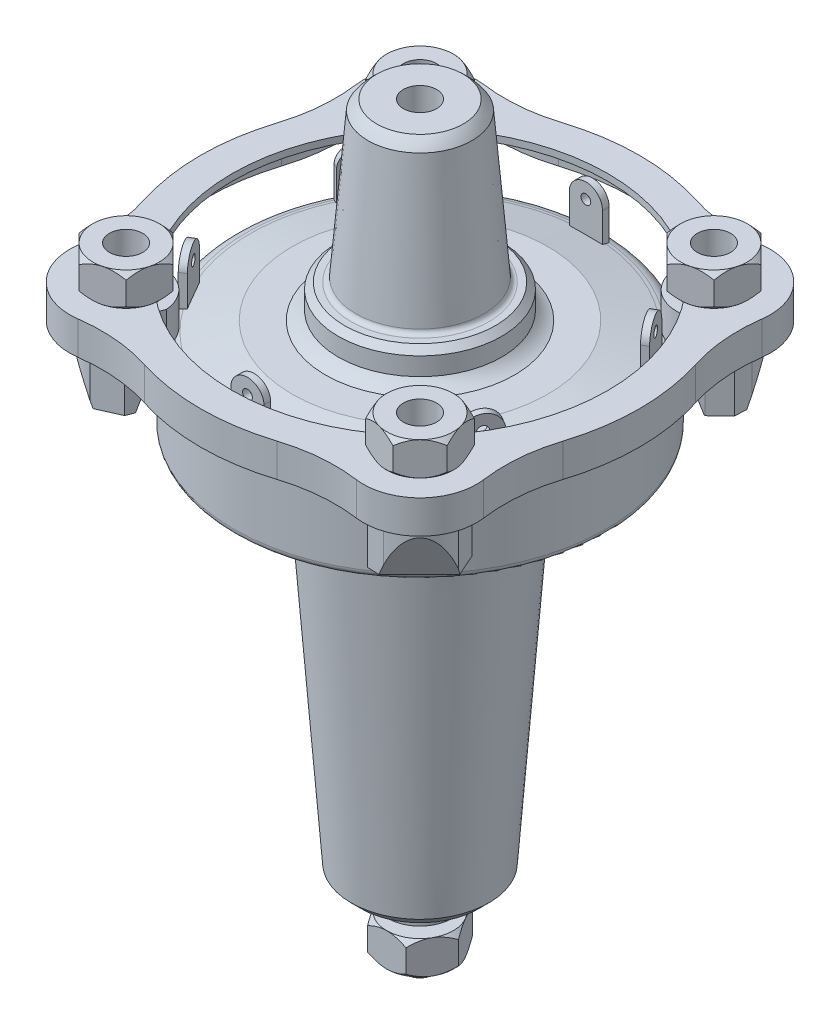
from build123d import *

# Parameters (mm, degrees)
BOSS_EXTRUDE1_DEPTH     = 10
SHELL1_T                = -2
BOSS_EXTRUDE2_DEPTH     = 25
CUT_EXTRUDE1_START      = -56.000013
CUT_EXTRUDE1_DEPTH      = 112.000026
CUT_EXTRUDE2_DEPTH      = 25
CUT_EXTRUDE2_DEPTH_BACK = 25
BOSS_EXTRUDE4_START     = 4
SKETCH11_R              = 5
BOSS_EXTRUDE4_DEPTH     = 55
BOSS_EXTRUDE5_START     = 0.2
SKETCH12_R              = 5
BOSS_EXTRUDE5_DEPTH     = 10
CIRPATTERN2_COUNT       = 4
BOSS_EXTRUDE6_START     = 3
SKETCH16_R              = 5
BOSS_EXTRUDE6_DEPTH     = 10
BOSS_EXTRUDE7_START     = 23
SKETCH19_W              = 10
SKETCH19_H              = 2
BOSS_EXTRUDE7_DEPTH     = 17
CUT_EXTRUDE3_DEPTH      = 3
SKETCH21_R              = 1.468360271
CUT_EXTRUDE4_DEPTH      = 2
CIRPATTERN3_COUNT       = 6
SKETCH22_R              = 5
CUT_EXTRUDE5_DEPTH      = 55


with BuildPart() as part:
    # Sketch1 → Revolve1 (revolve)
    with BuildSketch(Plane.XY, mode=Mode.PRIVATE) as revolve1_sk:
        with BuildLine():
            Line((-56, 20.318064045), (-56, 2.002164861))
            ThreePointArc((-56, 2.002164861), (-55.475282644, 0.643624038), (-54.168871694, 0))
            Line((-54.168871694, 0), (-40.294275716, 0))
            ThreePointArc((-40.294275716, 0), (-38.685602359, -0.47223007), (-38, -2.002191055))
            Line((-38, -2.002191055), (-38, -8))
            Line((-38, -8), (-33, -8))
            ThreePointArc((-33, -8), (-29.595355115, -9.338252711), (-28.013220329, -12.636642718))
            Line((-28.013220329, -12.636642718), (-20.700333224, -113))
            Line((-20.700333224, -113), (-17.700333224, -116))
            Line((-17.700333224, -116), (-5.005495065, -116))
            Line((-5.005495065, -116), (-5.005495065, 86))
            Line((-5.005495065, 86), (-13.005495065, 86))
            ThreePointArc((-13.005495065, 86), (-14.431764892, 84.590632691), (-15.652604552, 83))
            Line((-15.652604552, 83), (-19.242395009, 39.684629687))
            ThreePointArc((-19.242395009, 39.684629687), (-19.709520419, 38.7291334), (-20.700333224, 38.342520816))
            Line((-20.700333224, 38.342520816), (-22.700333224, 38.342520816))
            Line((-22.700333224, 38.342520816), (-24.567556452, 36.475294958))
            Line((-24.567556452, 36.475294958), (-24.567556452, 31.062035315))
            ThreePointArc((-24.567556452, 31.062035315), (-26.332636345, 29.455038721), (-28.44909, 28.35115059))
            Line((-28.44909, 28.35115059), (-38.44909, 28.35115059))
            Line((-38.44909, 28.35115059), (-51.056099295, 25.4407569))
            Line((-51.056099295, 25.4407569), (-52.126082775, 25.193981093))
            ThreePointArc((-52.126082775, 25.193981093), (-54.913630569, 23.43181587), (-56, 20.318064045))
        make_face()
    revolve(revolve1_sk.sketch.rotate(Axis((0, 166.474598928, 0), (0, -1, 0)), 270), axis=Axis((0, 166.474598928, 0), (0, -1, 0)))


with BuildPart() as body_2:
    # Sketch2 → Revolve2 (revolve)
    with BuildSketch(Plane.XY, mode=Mode.PRIVATE) as revolve2_sk:
        Polygon((-9.642767104, -116), (-9.642767104, -122.580289549), (-5.005495065, -122.580289549), (-5.005495065, -136), (-4.004428905, -140.07390495), (0, -140.07390495), (0, -116), align=None)
    revolve(revolve2_sk.sketch.rotate(Axis((0, 166.474598928, 0), (0, -1, 0)), 270), axis=Axis((0, 166.474598928, 0), (0, -1, 0)))


with BuildPart() as body_3:
    # Sketch3 → Boss-Extrude1 (new body)
    with BuildSketch(Plane(origin=(0, 28.35115059, 0), x_dir=(1, 0, 0), z_dir=(0, 1, 0))):
        with BuildLine():
            ThreePointArc((-62.91080264, 19.955723771), (-66, 0), (-62.91080264, -19.955723771))
            ThreePointArc((-62.91080264, -19.955723771), (-60.752328752, -30.813455346), (-61.035928635, -41.880022817))
            ThreePointArc((-61.035928635, -41.880022817), (-56.214989104, -56.214989104), (-41.880022817, -61.035928635))
            ThreePointArc((-41.880022817, -61.035928635), (-30.813455346, -60.752328752), (-19.955723771, -62.91080264))
            ThreePointArc((-19.955723771, -62.91080264), (0, -66), (19.955723771, -62.91080264))
            ThreePointArc((19.955723771, -62.91080264), (30.813455346, -60.752328752), (41.880022817, -61.035928635))
            ThreePointArc((41.880022817, -61.035928635), (56.214989104, -56.214989104), (61.035928635, -41.880022817))
            ThreePointArc((61.035928635, -41.880022817), (60.752328752, -30.813455346), (62.91080264, -19.955723771))
            ThreePointArc((62.91080264, -19.955723771), (66, 0), (62.91080264, 19.955723771))
            ThreePointArc((62.91080264, 19.955723771), (60.752328752, 30.813455346), (61.035928635, 41.880022817))
            ThreePointArc((61.035928635, 41.880022817), (56.214989104, 56.214989104), (41.880022817, 61.035928635))
            ThreePointArc((41.880022817, 61.035928635), (30.813455346, 60.752328752), (19.955723771, 62.91080264))
            ThreePointArc((19.955723771, 62.91080264), (0, 66), (-19.955723771, 62.91080264))
            ThreePointArc((-19.955723771, 62.91080264), (-30.813455346, 60.752328752), (-41.880022817, 61.035928635))
            ThreePointArc((-41.880022817, 61.035928635), (-56.214989104, 56.214989104), (-61.035928635, 41.880022817))
            ThreePointArc((-61.035928635, 41.880022817), (-60.752328752, 30.813455346), (-62.91080264, 19.955723771))
        make_face()
        with BuildLine():
            Line((-40.520048121, 47.585456814), (-36.630123502, 43.01725296))
            ThreePointArc((-36.630123502, 43.01725296), (0, 56.5), (36.630123502, 43.01725296))
            Line((36.630123502, 43.01725296), (40.520048121, 47.585456814))
            ThreePointArc((40.520048121, 47.585456814), (47.72970773, 47.72970773), (47.585456814, 40.520048121))
            Line((47.585456814, 40.520048121), (43.327741726, 36.262333033))
            ThreePointArc((43.327741726, 36.262333033), (56.5, 0), (43.327741726, -36.262333033))
            Line((43.327741726, -36.262333033), (47.585456814, -40.520048121))
            ThreePointArc((47.585456814, -40.520048121), (47.72970773, -47.72970773), (40.520048121, -47.585456814))
            Line((40.520048121, -47.585456814), (36.630123502, -43.01725296))
            ThreePointArc((36.630123502, -43.01725296), (0, -56.5), (-36.630123502, -43.01725296))
            Line((-36.630123502, -43.01725296), (-40.520048121, -47.585456814))
            ThreePointArc((-40.520048121, -47.585456814), (-47.72970773, -47.72970773), (-47.585456814, -40.520048121))
            Line((-47.585456814, -40.520048121), (-43.327741726, -36.262333033))
            ThreePointArc((-43.327741726, -36.262333033), (-56.5, 0), (-43.327741726, 36.262333033))
            Line((-43.327741726, 36.262333033), (-47.585456814, 40.520048121))
            ThreePointArc((-47.585456814, 40.520048121), (-47.72970773, 47.72970773), (-40.520048121, 47.585456814))
        make_face(mode=Mode.SUBTRACT)
    extrude(amount=BOSS_EXTRUDE1_DEPTH)

    # Shell1
    shell1_openings = [body_3.faces().sort_by_distance(p)[0] for p in [
        (-54.894989104, 28.35115059, -54.894989104),
        (-47.72970773, 33.35115059, -47.72970773),
        (-45.45659927, 33.35115059, -38.391190577),
        (-56.5, 33.35115059, 0),
        (-45.45659927, 33.35115059, 38.391190577),
        (-47.72970773, 33.35115059, 47.72970773),
        (-38.575085812, 33.35115059, 45.301354887),
        (0, 33.35115059, 56.5),
        (38.575085812, 33.35115059, 45.301354887),
        (47.72970773, 33.35115059, 47.72970773),
        (45.45659927, 33.35115059, 38.391190577),
        (56.5, 33.35115059, 0),
        (45.45659927, 33.35115059, -38.391190577),
        (47.72970773, 33.35115059, -47.72970773),
        (38.575085812, 33.35115059, -45.301354887),
        (0, 33.35115059, -56.5),
        (-38.575085812, 33.35115059, -45.301354887),
    ]]
    offset(amount=SHELL1_T, openings=shell1_openings, kind=Kind.INTERSECTION)


with BuildPart() as body_4:
    # Sketch6 → Boss-Extrude2 (new body)
    with BuildSketch(Plane.XZ.offset(-36.35115059)):
        with BuildLine():
            ThreePointArc((-55.421850464, -43.842867104), (-52.355337499, -51.912952653), (-44.468490076, -55.423995271))
            Line((-44.468490076, -55.423995271), (-39.444146313, -55.190090115))
            Line((-39.444146313, -55.190090115), (-35.000854716, -50.649173662))
            ThreePointArc((-35.000854716, -50.649173662), (-33.754234813, -48.340474897), (-33.0771803, -45.805568912))
            ThreePointArc((-33.0771803, -45.805568912), (-34.881524154, -44.446926471), (-36.630123502, -43.01725296))
            Line((-36.630123502, -43.01725296), (-38.236241256, -44.90342661))
            ThreePointArc((-38.236241256, -44.90342661), (-48.263713413, -48.603124667), (-45.377410146, -38.312001453))
            Line((-45.377410146, -38.312001453), (-43.327741726, -36.262333033))
            ThreePointArc((-43.327741726, -36.262333033), (-44.312355721, -35.052319901), (-45.263188405, -33.815584801))
            Line((-45.263188405, -33.815584801), (-52.230177703, -36.633284204))
            Line((-52.230177703, -36.633284204), (-55.421850464, -43.842867104))
        make_face()
        with BuildLine():
            ThreePointArc((-36.630123502, -43.01725296), (-34.881524154, -44.446926471), (-33.0771803, -45.805568912))
            ThreePointArc((-33.0771803, -45.805568912), (-35.398390317, -37.207162186), (-43.248717975, -33.000860982))
            Line((-43.248717975, -33.000860982), (-45.263188405, -33.815584801))
            ThreePointArc((-45.263188405, -33.815584801), (-44.312355721, -35.052319901), (-43.327741726, -36.262333033))
            Line((-43.327741726, -36.262333033), (-45.377410146, -38.312001453))
            ThreePointArc((-45.377410146, -38.312001453), (-40.392819982, -39.552007416), (-38.194173824, -44.194173824))
            ThreePointArc((-38.194173824, -44.194173824), (-38.204699915, -44.549423449), (-38.236241256, -44.90342661))
            Line((-38.236241256, -44.90342661), (-36.630123502, -43.01725296))
        make_face()
    extrude(amount=BOSS_EXTRUDE2_DEPTH)

    # Sketch9 → Cut-Extrude1 (cut)
    with BuildSketch(Plane(origin=(0, 0, 0), x_dir=(0.707106781186549, 0, 0.707106781186546), z_dir=(-0.707106781186546, 0, 0.707106781186549)).offset(CUT_EXTRUDE1_START)):
        with BuildLine():
            Line((-65.550163114, -3.044616932), (-56.435604944, 22.886666607))
            ThreePointArc((-56.435604944, 22.886666607), (-54.201485092, 25.672226359), (-50.743866449, 26.564138892))
            Line((-50.743866449, 26.564138892), (-50.743866449, -3.044616932))
            Line((-50.743866449, -3.044616932), (-65.550163114, -3.044616932))
        make_face()
    extrude(amount=CUT_EXTRUDE1_DEPTH, mode=Mode.SUBTRACT)

    # Sketch18 → Cut-Extrude2 (cut, two sides)
    with BuildSketch(Plane(origin=(0, 0, 0), x_dir=(0.707106781186549, 0, 0.707106781186546), z_dir=(-0.707106781186546, 0, 0.707106781186549))) as cut_extrude2_sk:
        Polygon((-73.733171375, 23.85115059), (-69.328029821, 10.767921848), (-73.733171375, 10.767921848), align=None)
    extrude(amount=CUT_EXTRUDE2_DEPTH, mode=Mode.SUBTRACT)
    extrude(cut_extrude2_sk.sketch, amount=-CUT_EXTRUDE2_DEPTH_BACK, mode=Mode.SUBTRACT)


with BuildPart() as body_5:
    # Sketch11 → Boss-Extrude4 (new body)
    with BuildSketch(Plane.XZ.offset(BOSS_EXTRUDE4_START)):
        with Locations(Location((-44.194173824, -44.194173824, 0), (0, 0, 270))):
            Circle(SKETCH11_R)
    extrude(amount=-BOSS_EXTRUDE4_DEPTH)


with BuildPart() as body_6:
    # Sketch12 → Boss-Extrude5 (new body)
    with BuildSketch(Plane(origin=(0, 38.35115059, 0), x_dir=(1, 0, 0), z_dir=(0, 1, 0)).offset(BOSS_EXTRUDE5_START)):
        Polygon((-47.182758731, 55.347724541), (-55.347724541, 47.182758731), (-52.359139633, 36.029208015), (-41.205588917, 33.040623108), (-33.040623108, 41.205588917), (-36.029208015, 52.359139633), align=None)
        with Locations(Location((-44.194173824, 44.194173824, 0), (0, 0, 270))):
            Circle(SKETCH12_R, mode=Mode.SUBTRACT)
    extrude(amount=BOSS_EXTRUDE5_DEPTH)

    # Sketch15 → Cut-Revolve6 (revolve, cut)
    with BuildSketch(Plane(origin=(0, 0, 0), x_dir=(0.707106781186549, 0, 0.707106781186546), z_dir=(-0.707106781186546, 0, 0.707106781186549)), mode=Mode.PRIVATE) as cut_revolve6_sk:
        Polygon((-75.337097631, 48.55115059), (-72.5, 48.55115059), (-75.337097631, 45.714052959), align=None)
        Polygon((-72.5, 38.55115059), (-75.337097631, 38.55115059), (-75.337097631, 41.388248221), align=None)
    revolve(cut_revolve6_sk.sketch.rotate(Axis((-44.194173824, 51, -44.194173824), (0, 1, 0)), 109.570402431), axis=Axis((-44.194173824, 51, -44.194173824), (0, 1, 0)), mode=Mode.SUBTRACT)


with BuildPart() as cirpattern2_1:
    # CirPattern2: pattern copy
    add(body_4.part.rotate(Axis((0, 0, 0), (0, 1, 0)), 1 * 360 / CIRPATTERN2_COUNT))


with BuildPart() as cirpattern2_2:
    # CirPattern2: pattern copy
    add(body_4.part.rotate(Axis((0, 0, 0), (0, 1, 0)), 2 * 360 / CIRPATTERN2_COUNT))


with BuildPart() as cirpattern2_3:
    # CirPattern2: pattern copy
    add(body_4.part.rotate(Axis((0, 0, 0), (0, 1, 0)), 3 * 360 / CIRPATTERN2_COUNT))


with BuildPart() as cirpattern2_4:
    # CirPattern2: pattern copy
    add(body_6.part.rotate(Axis((0, 0, 0), (0, 1, 0)), 1 * 360 / CIRPATTERN2_COUNT))


with BuildPart() as cirpattern2_5:
    # CirPattern2: pattern copy
    add(body_6.part.rotate(Axis((0, 0, 0), (0, 1, 0)), 2 * 360 / CIRPATTERN2_COUNT))


with BuildPart() as cirpattern2_6:
    # CirPattern2: pattern copy
    add(body_6.part.rotate(Axis((0, 0, 0), (0, 1, 0)), 3 * 360 / CIRPATTERN2_COUNT))


with BuildPart() as body_13:
    # Sketch16 → Boss-Extrude6 (new body)
    with BuildSketch(Plane.XZ.offset(122.580289549).offset(BOSS_EXTRUDE6_START)):
        Polygon((-5.773502692, 10), (-11.547005384, 0), (-5.773502692, -10), (5.773502692, -10), (11.547005384, 0), (5.773502692, 10), align=None)
        with Locations(Location((0, 0, 0), (0, 0, 270))):
            Circle(SKETCH16_R, mode=Mode.SUBTRACT)
    extrude(amount=BOSS_EXTRUDE6_DEPTH)

    # Sketch17 → Cut-Revolve7 (revolve, cut)
    with BuildSketch(Plane(origin=(0, 0, 0), x_dir=(0, 0, -1), z_dir=(1, 0, 0))):
        Polygon((-10, -125.580289549), (-13, -125.580289549), (-13, -128.580289549), align=None)
        Polygon((-10, -135.580289549), (-13, -135.580289549), (-13, -132.580289549), align=None)
    revolve(axis=Axis((0, -140.07390495, 0), (0, 1, 0)), mode=Mode.SUBTRACT)


with BuildPart() as body_14:
    # Sketch19 → Boss-Extrude7 (new body)
    with BuildSketch(Plane(origin=(0, 0, 0), x_dir=(1, 0, 0), z_dir=(0, 1, 0)).offset(BOSS_EXTRUDE7_START)):
        with Locations((0, 50.88572545)):
            Rectangle(SKETCH19_W, SKETCH19_H)
    extrude(amount=BOSS_EXTRUDE7_DEPTH)

    # Sketch20 → Cut-Extrude3 (cut)
    with BuildSketch(Plane.XY.offset(-49.88572545)):
        with BuildLine():
            Line((5, 34.487191817), (5, 40))
            Line((5, 40), (-5, 40))
            Line((-5, 40), (-5, 34.821281199))
            ThreePointArc((-5, 34.821281199), (0.161557103, 39.489981432), (5, 34.487191817))
        make_face()
    extrude(amount=-CUT_EXTRUDE3_DEPTH, mode=Mode.SUBTRACT)

    # Sketch21 → Cut-Extrude4 (cut)
    with BuildSketch(Plane.XY.offset(-49.88572545)):
        with Locations((0, 34.919429922)):
            Circle(SKETCH21_R)
    extrude(amount=-CUT_EXTRUDE4_DEPTH, mode=Mode.SUBTRACT)


with BuildPart() as cirpattern3_1:
    # CirPattern3: pattern copy
    add(body_14.part.rotate(Axis((0, 0, 0), (0, 1, 0)), 1 * 360 / CIRPATTERN3_COUNT))


with BuildPart() as cirpattern3_2:
    # CirPattern3: pattern copy
    add(body_14.part.rotate(Axis((0, 0, 0), (0, 1, 0)), 2 * 360 / CIRPATTERN3_COUNT))


with BuildPart() as cirpattern3_3:
    # CirPattern3: pattern copy
    add(body_14.part.rotate(Axis((0, 0, 0), (0, 1, 0)), 3 * 360 / CIRPATTERN3_COUNT))


with BuildPart() as cirpattern3_4:
    # CirPattern3: pattern copy
    add(body_14.part.rotate(Axis((0, 0, 0), (0, 1, 0)), 4 * 360 / CIRPATTERN3_COUNT))


with BuildPart() as cirpattern3_5:
    # CirPattern3: pattern copy
    add(body_14.part.rotate(Axis((0, 0, 0), (0, 1, 0)), 5 * 360 / CIRPATTERN3_COUNT))


with BuildPart() as cut_extrude5_tool:
    # Sketch22 → Cut-Extrude5 (new body)
    with BuildSketch(Plane(origin=(0, 51, 0), x_dir=(1, 0, 0), z_dir=(0, 1, 0))):
        with Locations(Location((-44.194173824, 44.194173824, 0), (0, 0, 270))):
            Circle(SKETCH22_R)
    extrude(amount=-CUT_EXTRUDE5_DEPTH)


with BuildPart() as body_3_1:
    add(body_3.part)

    # Cut-Extrude5: cut by cut_extrude5_tool
    add(cut_extrude5_tool.part, mode=Mode.SUBTRACT)


with BuildPart() as body_5_1:
    add(body_5.part)

    # Cut-Extrude5: cut by cut_extrude5_tool
    add(cut_extrude5_tool.part, mode=Mode.SUBTRACT)


solid = Compound([part.part, body_2.part, body_4.part, body_6.part, cirpattern2_1.part, cirpattern2_2.part, cirpattern2_3.part, cirpattern2_4.part, cirpattern2_5.part, cirpattern2_6.part, body_13.part, body_14.part, cirpattern3_1.part, cirpattern3_2.part, cirpattern3_3.part, cirpattern3_4.part, cirpattern3_5.part, body_3_1.part])
